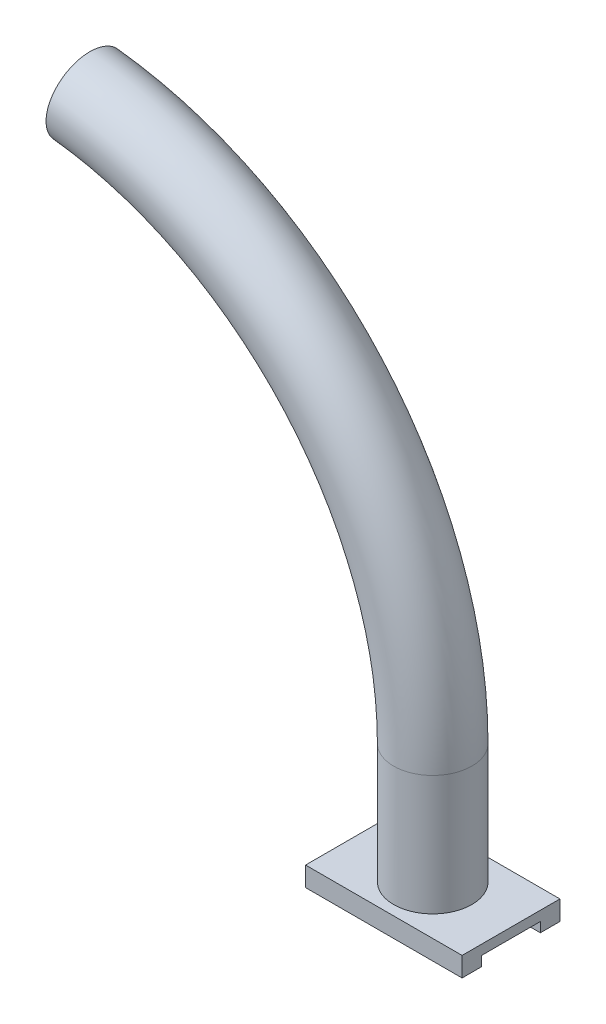
from build123d import *

# Parameters (mm, degrees)
SKETCH1_W           = 8
SKETCH1_H           = 5
BOSS_EXTRUDE1_DEPTH = 0.5
SKETCH2_W           = 8
SKETCH2_H           = 1
BOSS_EXTRUDE2_DEPTH = 0.5
SKETCH3_R           = 2
BOSS_EXTRUDE3_DEPTH = 1
SWEEP5_PROFILE_R    = 2


with BuildPart() as part:
    # Sketch1 → Boss-Extrude1 (new body)
    with BuildSketch(Plane(origin=(0, 0, 0), x_dir=(1, 0, 0), z_dir=(0, 1, 0))):
        with Locations((4, 2.5)):
            Rectangle(SKETCH1_W, SKETCH1_H)
    extrude(amount=BOSS_EXTRUDE1_DEPTH)

    # Sketch2 → Boss-Extrude2 (add)
    with BuildSketch(Plane.XZ):
        with Locations((4, -0.5)):
            Rectangle(SKETCH2_W, SKETCH2_H)
        with Locations((4, -4.5)):
            Rectangle(SKETCH2_W, SKETCH2_H)
    extrude(amount=BOSS_EXTRUDE2_DEPTH)

    # Sketch3 → Boss-Extrude3 (add)
    with BuildSketch(Plane(origin=(0, 0.5, 0), x_dir=(1, 0, 0), z_dir=(0, 1, 0))):
        with Locations((4, 2.5)):
            Circle(SKETCH3_R)
    extrude(amount=BOSS_EXTRUDE3_DEPTH)

    # Sweep5: sweep along a path in Sketch6
    with BuildLine(Plane.XY.offset(-2.5)) as sweep5_path:
        Line((4, 1.5), (4, 6.626951227))
        ThreePointArc((4, 6.626951227), (-1.083608385, 19.949911153), (-13.750126119, 26.5))
    # Sweep5 profile (on start of the path) → Sweep5 (sweep)
    with BuildSketch(Plane(origin=(4, 1.5, -2.5), x_dir=(1, 0, 0), z_dir=(0, 1, 0))):
        Circle(SWEEP5_PROFILE_R)
    sweep(path=sweep5_path.line)


solid = part.part
